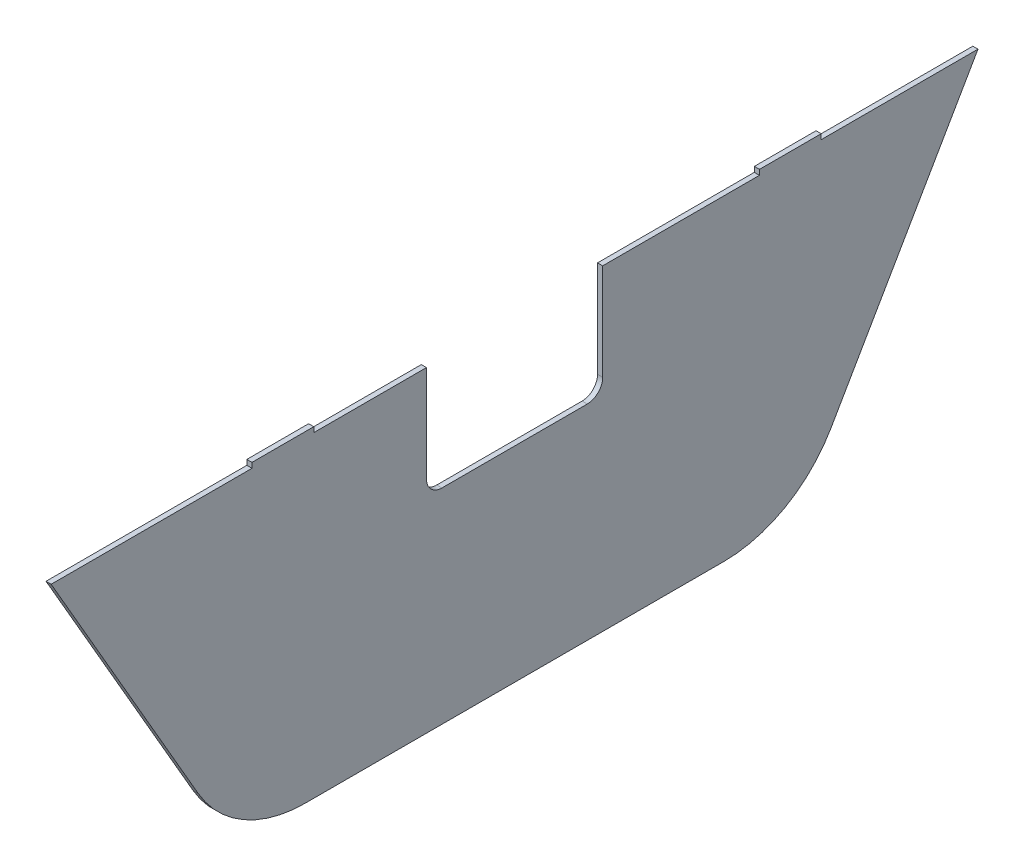
from build123d import *

# Parameters (mm, degrees)
BOSS_EXTRUDE1_DEPTH = 2


with BuildPart() as part:
    # Sketch3 → Boss-Extrude1 (new body)
    with BuildSketch(Plane(origin=(0, 0, 0), x_dir=(0, 0, -1), z_dir=(1, 0, 0))):
        with BuildLine():
            Line((-58.824606693, -2534.80652233), (-1.666930044, -2633.80652233))
            ThreePointArc((-1.666930044, -2633.80652233), (15.902289338, -2651.375741711), (39.902289338, -2657.80652233))
            Line((39.902289338, -2657.80652233), (202.448497275, -2657.80652233))
            ThreePointArc((202.448497275, -2657.80652233), (226.448497275, -2651.375741711), (244.017716657, -2633.80652233))
            Line((244.017716657, -2633.80652233), (301.175393307, -2534.80652233))
            Line((301.175393307, -2534.80652233), (240.287893307, -2534.80652233))
            Line((240.287893307, -2534.80652233), (240.287893307, -2532.80652233))
            Line((240.287893307, -2532.80652233), (216.287893307, -2532.80652233))
            Line((216.287893307, -2532.80652233), (216.287893307, -2534.80652233))
            Line((216.287893307, -2534.80652233), (155.400393307, -2534.80652233))
            Line((155.400393307, -2534.80652233), (155.400393307, -2572.30652233))
            ThreePointArc((155.400393307, -2572.30652233), (153.643033994, -2576.549163017), (149.400393307, -2578.30652233))
            Line((149.400393307, -2578.30652233), (92.950393307, -2578.30652233))
            ThreePointArc((92.950393307, -2578.30652233), (88.70775262, -2576.549163017), (86.950393307, -2572.30652233))
            Line((86.950393307, -2572.30652233), (86.950393307, -2534.80652233))
            Line((86.950393307, -2534.80652233), (43.175393307, -2534.80652233))
            Line((43.175393307, -2534.80652233), (43.175393307, -2532.80652233))
            Line((43.175393307, -2532.80652233), (19.175393307, -2532.80652233))
            Line((19.175393307, -2532.80652233), (19.175393307, -2534.80652233))
            Line((19.175393307, -2534.80652233), (-58.824606693, -2534.80652233))
        make_face()
    extrude(amount=BOSS_EXTRUDE1_DEPTH)


solid = part.part
